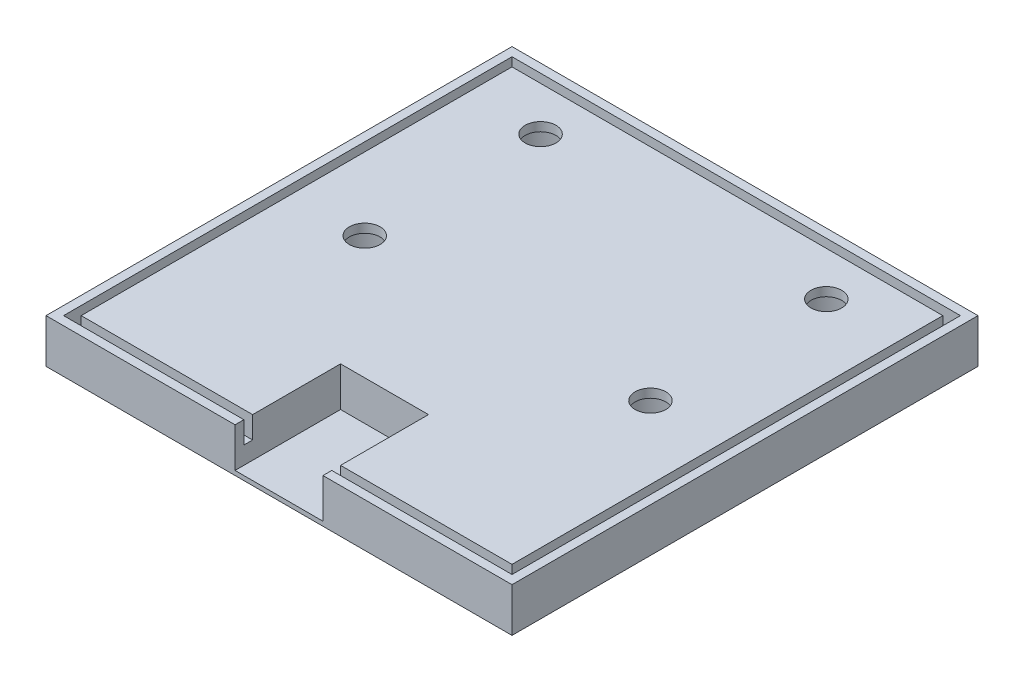
from build123d import *

# Parameters (mm, degrees)
BOSS_EXTRUDE1_DEPTH   = 10
SKETCH1_R             = 3.5
BOSS_EXTRUDE1_2_DEPTH = 10
BOSS_EXTRUDE2_DEPTH   = 5
SKETCH1_6_W           = 20
SKETCH1_6_H           = 24
BOSS_EXTRUDE3_DEPTH   = 1
SKETCH1_7_R           = 8.5
SKETCH1_7_R_2         = 3.5
CUT_EXTRUDE1_DEPTH    = 8
SKETCH2_R             = 10.261268268
SKETCH2_R_2           = 10.194878558
CUT_EXTRUDE4_DEPTH    = 8


with BuildPart() as part:
    # Sketch1 → Boss-Extrude1 (new body)
    with BuildSketch(Plane(origin=(0, 0, 0), x_dir=(1, 0, 0), z_dir=(0, 1, 0))):
        Polygon((0, -102), (0, 0), (102, 0), (102, -102), (61, -102), (61, -104), (104, -104), (104, 2), (-2, 2), (-2, -104), (41, -104), (41, -102), align=None)
    extrude(amount=BOSS_EXTRUDE1_DEPTH)



with BuildPart() as body_2:
    # Sketch1 → Boss-Extrude1 2 (new body)
    with BuildSketch(Plane(origin=(0, 0, 0), x_dir=(1, 0, 0), z_dir=(0, 1, 0))):
        Polygon((2, -100), (41, -100), (41, -80), (61, -80), (61, -100), (100, -100), (100, -2), (2, -2), align=None)
        with Locations((18.5, -52)):
            Circle(SKETCH1_R, mode=Mode.SUBTRACT)
        with Locations((83.5, -52)):
            Circle(SKETCH1_R, mode=Mode.SUBTRACT)
        with Locations((18.5, -12)):
            Circle(SKETCH1_R, mode=Mode.SUBTRACT)
        with Locations((83.5, -12)):
            Circle(SKETCH1_R, mode=Mode.SUBTRACT)
    extrude(amount=BOSS_EXTRUDE1_2_DEPTH)


with BuildPart() as part_1:
    add(part.part)

    add(body_2.part)  # Boss-Extrude2 merges body 2
    # Sketch1_5 → Boss-Extrude2 (add)
    with BuildSketch(Plane(origin=(0, 0, 0), x_dir=(1, 0, 0), z_dir=(0, 1, 0))):
        Polygon((102, 0), (0, 0), (0, -102), (41, -102), (41, -100), (2, -100), (2, -2), (100, -2), (100, -100), (61, -100), (61, -102), (102, -102), align=None)
    extrude(amount=BOSS_EXTRUDE2_DEPTH)

    # Sketch1_6 → Boss-Extrude3 (add)
    with BuildSketch(Plane(origin=(0, 0, 0), x_dir=(1, 0, 0), z_dir=(0, 1, 0))):
        with Locations((51, -92)):
            Rectangle(SKETCH1_6_W, SKETCH1_6_H)
    extrude(amount=BOSS_EXTRUDE3_DEPTH)

    # Sketch1_7 → Cut-Extrude1 (cut)
    # profile 1 of 4: a face of its own
    with BuildSketch(Plane(origin=(0, 0, 0), x_dir=(1, 0, 0), z_dir=(0, 1, 0))):
        with Locations((18.5, -12)):
            Circle(SKETCH1_7_R)
        with Locations((18.5, -12)):
            Circle(SKETCH1_7_R_2, mode=Mode.SUBTRACT)
    # profile 2 of 4: a face of its own
    with BuildSketch(Plane(origin=(0, 0, 0), x_dir=(1, 0, 0), z_dir=(0, 1, 0))):
        with Locations((83.5, -12)):
            Circle(SKETCH1_7_R)
        with Locations((83.5, -12)):
            Circle(SKETCH1_7_R_2, mode=Mode.SUBTRACT)
    # profile 3 of 4: a face of its own
    with BuildSketch(Plane(origin=(0, 0, 0), x_dir=(1, 0, 0), z_dir=(0, 1, 0))):
        with Locations((18.5, -52)):
            Circle(SKETCH1_7_R)
        with Locations((18.5, -52)):
            Circle(SKETCH1_7_R_2, mode=Mode.SUBTRACT)
    # profile 4 of 4: a face of its own
    with BuildSketch(Plane(origin=(0, 0, 0), x_dir=(1, 0, 0), z_dir=(0, 1, 0))):
        with Locations((83.5, -52)):
            Circle(SKETCH1_7_R)
        with Locations((83.5, -52)):
            Circle(SKETCH1_7_R_2, mode=Mode.SUBTRACT)
    extrude(amount=CUT_EXTRUDE1_DEPTH, mode=Mode.SUBTRACT)

    # Sketch2 → Cut-Extrude4 (cut)
    with BuildSketch(Plane.XZ):
        with BuildLine():
            Line((98, 4.574503774), (98, 98))
            Line((98, 98), (63, 98))
            Line((63, 98), (63, 76))
            Line((63, 76), (51, 76))
            Line((51, 76), (39, 76))
            Line((39, 76), (39, 98))
            Line((39, 98), (4, 98))
            Line((4, 98), (4, 4.574503774))
            Line((4, 4.574503774), (10.545814352, 4.574503774))
            ThreePointArc((10.545814352, 4.574503774), (14.509161453, 22.123253983), (29.381500977, 12))
            ThreePointArc((29.381500977, 12), (28.623253983, 8.009161453), (26.454185648, 4.574503774))
            Line((26.454185648, 4.574503774), (76.37304098, 4.574503774))
            ThreePointArc((76.37304098, 4.574503774), (79.46399305, 21.467955797), (93.792304848, 12))
            ThreePointArc((93.792304848, 12), (92.967955797, 7.96399305), (90.62695902, 4.574503774))
            Line((90.62695902, 4.574503774), (98, 4.574503774))
        make_face()
        with Locations((18.5, 52)):
            Circle(SKETCH2_R, mode=Mode.SUBTRACT)
        with Locations((83.5, 52)):
            Circle(SKETCH2_R_2, mode=Mode.SUBTRACT)
    extrude(amount=-CUT_EXTRUDE4_DEPTH, mode=Mode.SUBTRACT)


solid = part_1.part
